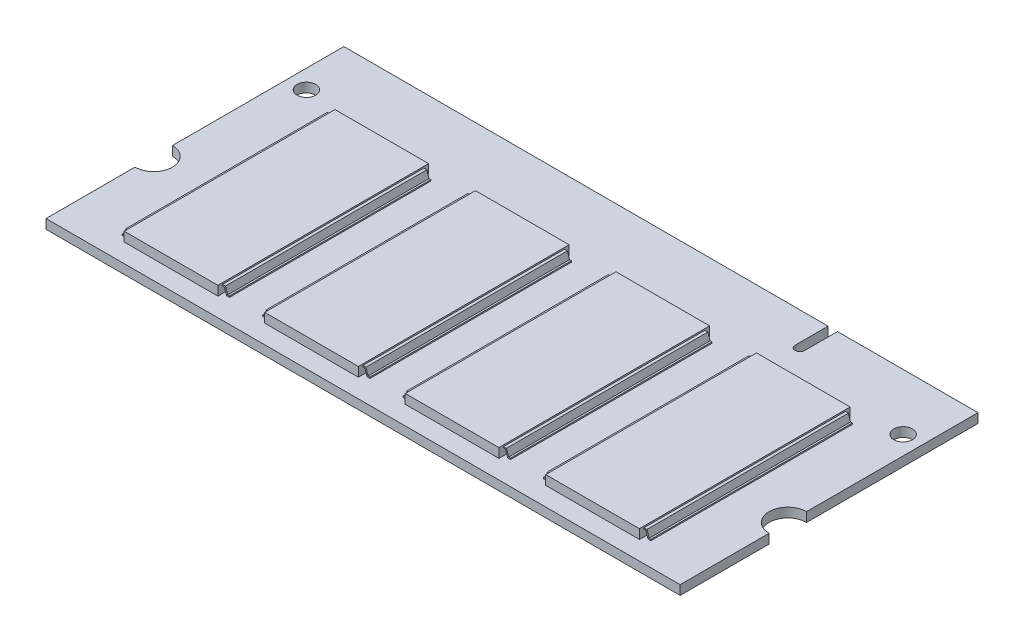
from build123d import *

# Parameters (mm, degrees)
CROQUIS1_R       = 1
EXTRUIR1_DEPTH   = 1
CROQUIS2_W       = 10
CROQUIS2_H       = 22.5
EXTRUIR2_DEPTH   = 1
EXTRUIR2_2_DEPTH = 1
EXTRUIR2_3_DEPTH = 1
EXTRUIR2_4_DEPTH = 1
EXTRUIR3_DEPTH   = 21.5
EXTRUIR3_2_DEPTH = 21.5
EXTRUIR3_3_DEPTH = 21.5
EXTRUIR3_4_DEPTH = 21.5
EXTRUIR3_5_DEPTH = 21.5
EXTRUIR3_6_DEPTH = 21.5
EXTRUIR3_7_DEPTH = 21.5
EXTRUIR3_8_DEPTH = 21.5


with BuildPart() as part:
    # Croquis1 → Extruir1 (new body)
    with BuildSketch(Plane(origin=(0, 0, 0), x_dir=(1, 0, 0), z_dir=(0, 1, 0))):
        with BuildLine():
            Line((33.85, 9.5), (33.85, 0))
            Line((33.85, 0), (-33.85, 0))
            Line((-33.85, 0), (-33.85, 9.5))
            ThreePointArc((-33.85, 9.5), (-31.85, 11.5), (-33.85, 13.5))
            Line((-33.85, 13.5), (-33.85, 31.8))
            Line((-33.85, 31.8), (17.85, 31.8))
            Line((17.85, 31.8), (17.85, 28.25))
            ThreePointArc((17.85, 28.25), (17.981801948, 27.931801948), (18.3, 27.8))
            Line((18.3, 27.8), (18.4, 27.8))
            ThreePointArc((18.4, 27.8), (18.718198052, 27.931801948), (18.85, 28.25))
            Line((18.85, 28.25), (18.85, 31.8))
            Line((18.85, 31.8), (33.85, 31.8))
            Line((33.85, 31.8), (33.85, 13.5))
            ThreePointArc((33.85, 13.5), (31.85, 11.5), (33.85, 9.5))
        make_face()
        with Locations((31.85, 25.8)):
            Circle(CROQUIS1_R, mode=Mode.SUBTRACT)
        with Locations((-31.85, 25.8)):
            Circle(CROQUIS1_R, mode=Mode.SUBTRACT)
    extrude(amount=EXTRUIR1_DEPTH)


with BuildPart() as body_2:
    # Croquis2 → Extruir2 (new body)
    with BuildSketch(Plane(origin=(0, 1, 0), x_dir=(-1, 0, 0), z_dir=(0, 1, 0))):
        with Locations((7.5, -13.25)):
            Rectangle(CROQUIS2_W, CROQUIS2_H)
    extrude(amount=EXTRUIR2_DEPTH)


with BuildPart() as body_3:
    # Croquis2 → Extruir2 2 (new body)
    with BuildSketch(Plane(origin=(0, 1, 0), x_dir=(-1, 0, 0), z_dir=(0, 1, 0))):
        with Locations((22.5, -13.25)):
            Rectangle(CROQUIS2_W, CROQUIS2_H)
    extrude(amount=EXTRUIR2_2_DEPTH)


with BuildPart() as body_4:
    # Croquis2 → Extruir2 3 (new body)
    with BuildSketch(Plane(origin=(0, 1, 0), x_dir=(-1, 0, 0), z_dir=(0, 1, 0))):
        with Locations((-22.5, -13.25)):
            Rectangle(CROQUIS2_W, CROQUIS2_H)
    extrude(amount=EXTRUIR2_3_DEPTH)


with BuildPart() as body_5:
    # Croquis2 → Extruir2 4 (new body)
    with BuildSketch(Plane(origin=(0, 1, 0), x_dir=(-1, 0, 0), z_dir=(0, 1, 0))):
        with Locations((-7.5, -13.25)):
            Rectangle(CROQUIS2_W, CROQUIS2_H)
    extrude(amount=EXTRUIR2_4_DEPTH)


with BuildPart() as body_6:
    # Croquis3 → Extruir3 (new body)
    with BuildSketch(Plane(origin=(0, 0, -24), x_dir=(-1, 0, 0), z_dir=(0, 0, -1))):
        Polygon((27.5, 1.838454184), (27.80957835, 1.838454184), (28.043008569, 1.138163525), (28.232670623, 1.138163525), (28.232670623, 1), (27.926293459, 1), (27.692264471, 1.702086966), (27.5, 1.702086966), align=None)
    extrude(amount=-EXTRUIR3_DEPTH)


with BuildPart() as body_7:
    # Croquis3 → Extruir3 2 (new body)
    with BuildSketch(Plane(origin=(0, 0, -24), x_dir=(-1, 0, 0), z_dir=(0, 0, -1))):
        Polygon((17.5, 1.702086966), (17.5, 1.838454184), (17.19042165, 1.838454184), (16.956991431, 1.138163525), (16.767329377, 1.138163525), (16.767329377, 1), (17.073706541, 1), (17.307735529, 1.702086966), align=None)
    extrude(amount=-EXTRUIR3_2_DEPTH)


with BuildPart() as body_8:
    # Croquis3 → Extruir3 3 (new body)
    with BuildSketch(Plane(origin=(0, 0, -24), x_dir=(-1, 0, 0), z_dir=(0, 0, -1))):
        Polygon((1.767329377, 1), (2.073706541, 1), (2.307735529, 1.702086966), (2.5, 1.702086966), (2.5, 1.838454184), (2.19042165, 1.838454184), (1.956991431, 1.138163525), (1.767329377, 1.138163525), align=None)
    extrude(amount=-EXTRUIR3_3_DEPTH)


with BuildPart() as body_9:
    # Croquis3 → Extruir3 4 (new body)
    with BuildSketch(Plane(origin=(0, 0, -24), x_dir=(-1, 0, 0), z_dir=(0, 0, -1))):
        Polygon((12.80957835, 1.838454184), (13.043008569, 1.138163525), (13.232670623, 1.138163525), (13.232670623, 1), (12.926293459, 1), (12.692264471, 1.702086966), (12.5, 1.702086966), (12.5, 1.838454184), align=None)
    extrude(amount=-EXTRUIR3_4_DEPTH)


with BuildPart() as body_10:
    # Croquis3 → Extruir3 5 (new body)
    with BuildSketch(Plane(origin=(0, 0, -24), x_dir=(-1, 0, 0), z_dir=(0, 0, -1))):
        Polygon((-13.232670623, 1), (-12.926293459, 1), (-12.692264471, 1.702086966), (-12.5, 1.702086966), (-12.5, 1.838454184), (-12.80957835, 1.838454184), (-13.043008569, 1.138163525), (-13.232670623, 1.138163525), align=None)
    extrude(amount=-EXTRUIR3_5_DEPTH)


with BuildPart() as body_11:
    # Croquis3 → Extruir3 6 (new body)
    with BuildSketch(Plane(origin=(0, 0, -24), x_dir=(-1, 0, 0), z_dir=(0, 0, -1))):
        Polygon((-2.19042165, 1.838454184), (-1.956991431, 1.138163525), (-1.767329377, 1.138163525), (-1.767329377, 1), (-2.073706541, 1), (-2.307735529, 1.702086966), (-2.5, 1.702086966), (-2.5, 1.838454184), align=None)
    extrude(amount=-EXTRUIR3_6_DEPTH)


with BuildPart() as body_12:
    # Croquis3 → Extruir3 7 (new body)
    with BuildSketch(Plane(origin=(0, 0, -24), x_dir=(-1, 0, 0), z_dir=(0, 0, -1))):
        Polygon((-28.232670623, 1), (-27.926293459, 1), (-27.692264471, 1.702086966), (-27.5, 1.702086966), (-27.5, 1.838454184), (-27.80957835, 1.838454184), (-28.043008569, 1.138163525), (-28.232670623, 1.138163525), align=None)
    extrude(amount=-EXTRUIR3_7_DEPTH)


with BuildPart() as body_13:
    # Croquis3 → Extruir3 8 (new body)
    with BuildSketch(Plane(origin=(0, 0, -24), x_dir=(-1, 0, 0), z_dir=(0, 0, -1))):
        Polygon((-17.19042165, 1.838454184), (-16.956991431, 1.138163525), (-16.767329377, 1.138163525), (-16.767329377, 1), (-17.073706541, 1), (-17.307735529, 1.702086966), (-17.5, 1.702086966), (-17.5, 1.838454184), align=None)
    extrude(amount=-EXTRUIR3_8_DEPTH)


with BuildPart() as body_14:
    # Simetría2: mirrored copy
    add(body_4.part.mirror(Plane.ZX.offset(0.5)))


with BuildPart() as body_15:
    # Simetr_a2 2: mirrored copy
    add(body_5.part.mirror(Plane.ZX.offset(0.5)))


with BuildPart() as body_16:
    # Simetr_a2 3: mirrored copy
    add(body_2.part.mirror(Plane.ZX.offset(0.5)))


with BuildPart() as body_17:
    # Simetr_a2 4: mirrored copy
    add(body_3.part.mirror(Plane.ZX.offset(0.5)))


with BuildPart() as body_18:
    # Simetr_a2 5: mirrored copy
    add(body_9.part.mirror(Plane.ZX.offset(0.5)))


with BuildPart() as body_19:
    # Simetr_a2 6: mirrored copy
    add(body_6.part.mirror(Plane.ZX.offset(0.5)))


with BuildPart() as body_20:
    # Simetr_a2 7: mirrored copy
    add(body_11.part.mirror(Plane.ZX.offset(0.5)))


with BuildPart() as body_21:
    # Simetr_a2 8: mirrored copy
    add(body_13.part.mirror(Plane.ZX.offset(0.5)))


with BuildPart() as body_22:
    # Simetr_a2 9: mirrored copy
    add(body_12.part.mirror(Plane.ZX.offset(0.5)))


with BuildPart() as body_23:
    # Simetr_a2 10: mirrored copy
    add(body_10.part.mirror(Plane.ZX.offset(0.5)))


with BuildPart() as body_24:
    # Simetr_a2 11: mirrored copy
    add(body_8.part.mirror(Plane.ZX.offset(0.5)))


with BuildPart() as body_25:
    # Simetr_a2 12: mirrored copy
    add(body_7.part.mirror(Plane.ZX.offset(0.5)))


solid = Compound([part.part, body_2.part, body_3.part, body_4.part, body_5.part, body_6.part, body_7.part, body_8.part, body_9.part, body_10.part, body_11.part, body_12.part, body_13.part, body_14.part, body_15.part, body_16.part, body_17.part, body_18.part, body_19.part, body_20.part, body_21.part, body_22.part, body_23.part, body_24.part, body_25.part])
